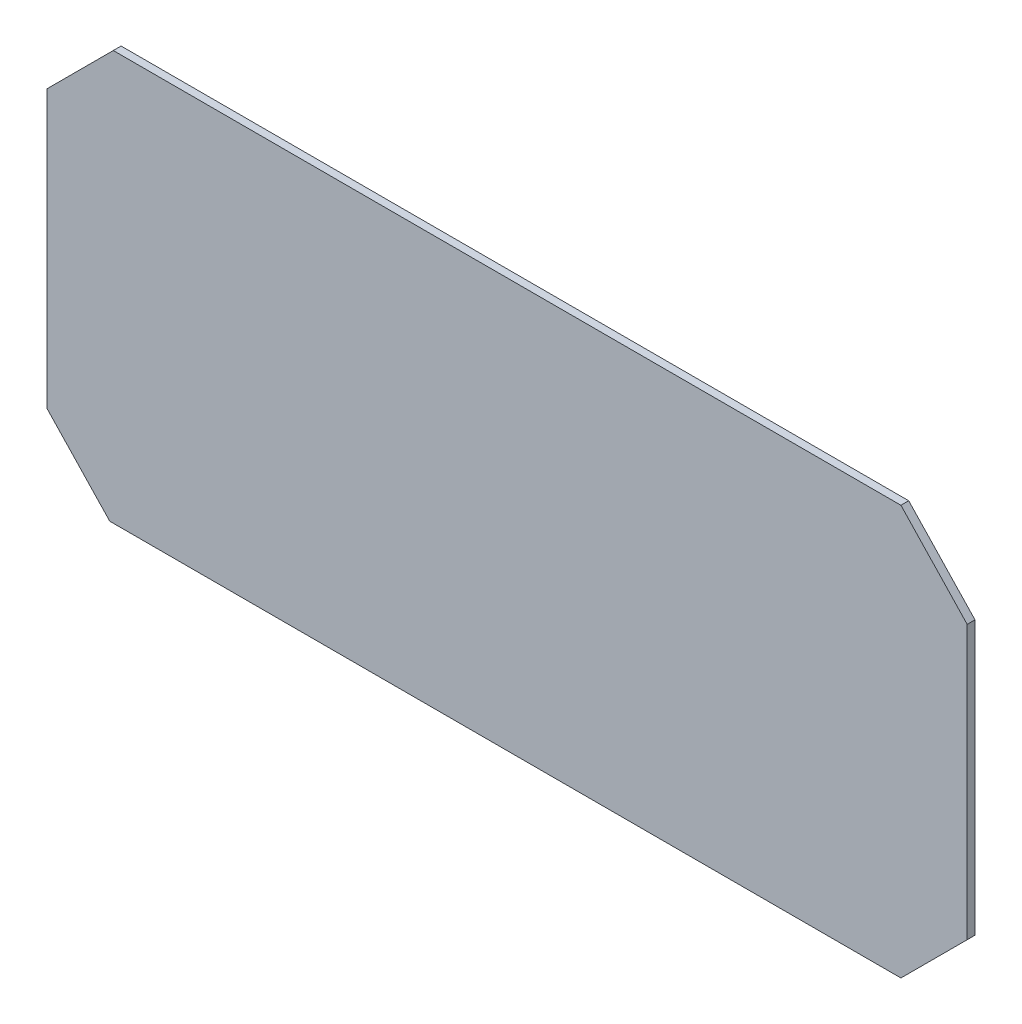
from build123d import *

# Parameters (mm, degrees)
BOSS_EXTRU_1_DEPTH = 2


with BuildPart() as part:
    # Esquisse1 → Boss.-Extru.1 (new body)
    with BuildSketch(Plane.XY):
        Polygon((0, -17), (0, -88), (16.093261094, -105), (219, -105), (236, -88), (236, -17.957827087), (219, 0), (17, 0), align=None)
    extrude(amount=BOSS_EXTRU_1_DEPTH)


solid = part.part
